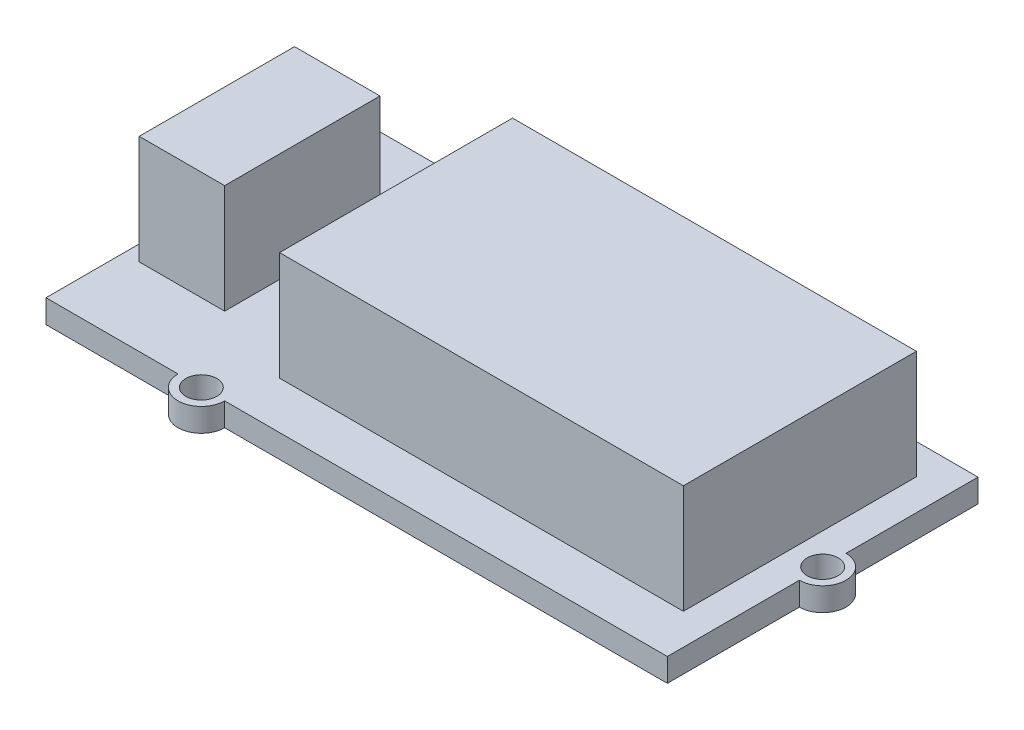
from build123d import *

# Parameters (mm, degrees)
SKETCH1_W           = 40
SKETCH1_H           = 20
BOSS_EXTRUDE1_DEPTH = 1.5
SKETCH2_R           = 1.5
BOSS_EXTRUDE3_DEPTH = 1.5
SKETCH3_R           = 1
CUT_EXTRUDE1_DEPTH  = 1.5
SKETCH4_W           = 5.5
SKETCH4_H           = 10
BOSS_EXTRUDE4_DEPTH = 7
SKETCH5_W           = 26
SKETCH5_H           = 15
BOSS_EXTRUDE5_DEPTH = 7


with BuildPart() as part:
    # Sketch1 → Boss-Extrude1 (new body)
    with BuildSketch(Plane(origin=(0, 0, 0), x_dir=(1, 0, 0), z_dir=(0, 1, 0))):
        Rectangle(SKETCH1_W, SKETCH1_H)
    extrude(amount=BOSS_EXTRUDE1_DEPTH)

    # Sketch2 → Boss-Extrude3 (add)
    with BuildSketch(Plane(origin=(0, 1.5, 0), x_dir=(1, 0, 0), z_dir=(0, 1, 0))):
        with Locations((-10, 10)):
            Circle(SKETCH2_R)
        with Locations((-10, -10)):
            Circle(SKETCH2_R)
        with Locations((20, 0)):
            Circle(SKETCH2_R)
    extrude(amount=-BOSS_EXTRUDE3_DEPTH)

    # Sketch3 → Cut-Extrude1 (cut)
    with BuildSketch(Plane(origin=(0, 1.5, 0), x_dir=(1, 0, 0), z_dir=(0, 1, 0))):
        with Locations((-10, -10)):
            Circle(SKETCH3_R)
        with Locations((20, 0)):
            Circle(SKETCH3_R)
        with Locations((-10, 10)):
            Circle(SKETCH3_R)
    extrude(amount=-CUT_EXTRUDE1_DEPTH, mode=Mode.SUBTRACT)

    # Sketch4 → Boss-Extrude4 (add)
    with BuildSketch(Plane(origin=(0, 1.5, 0), x_dir=(1, 0, 0), z_dir=(0, 1, 0))):
        with Locations((-16.25, 0)):
            Rectangle(SKETCH4_W, SKETCH4_H)
    extrude(amount=BOSS_EXTRUDE4_DEPTH)

    # Sketch5 → Boss-Extrude5 (add)
    with BuildSketch(Plane(origin=(0, 1.5, 0), x_dir=(1, 0, 0), z_dir=(0, 1, 0))):
        with Locations((5, 0.53388581)):
            Rectangle(SKETCH5_W, SKETCH5_H)
    extrude(amount=BOSS_EXTRUDE5_DEPTH)


solid = part.part
